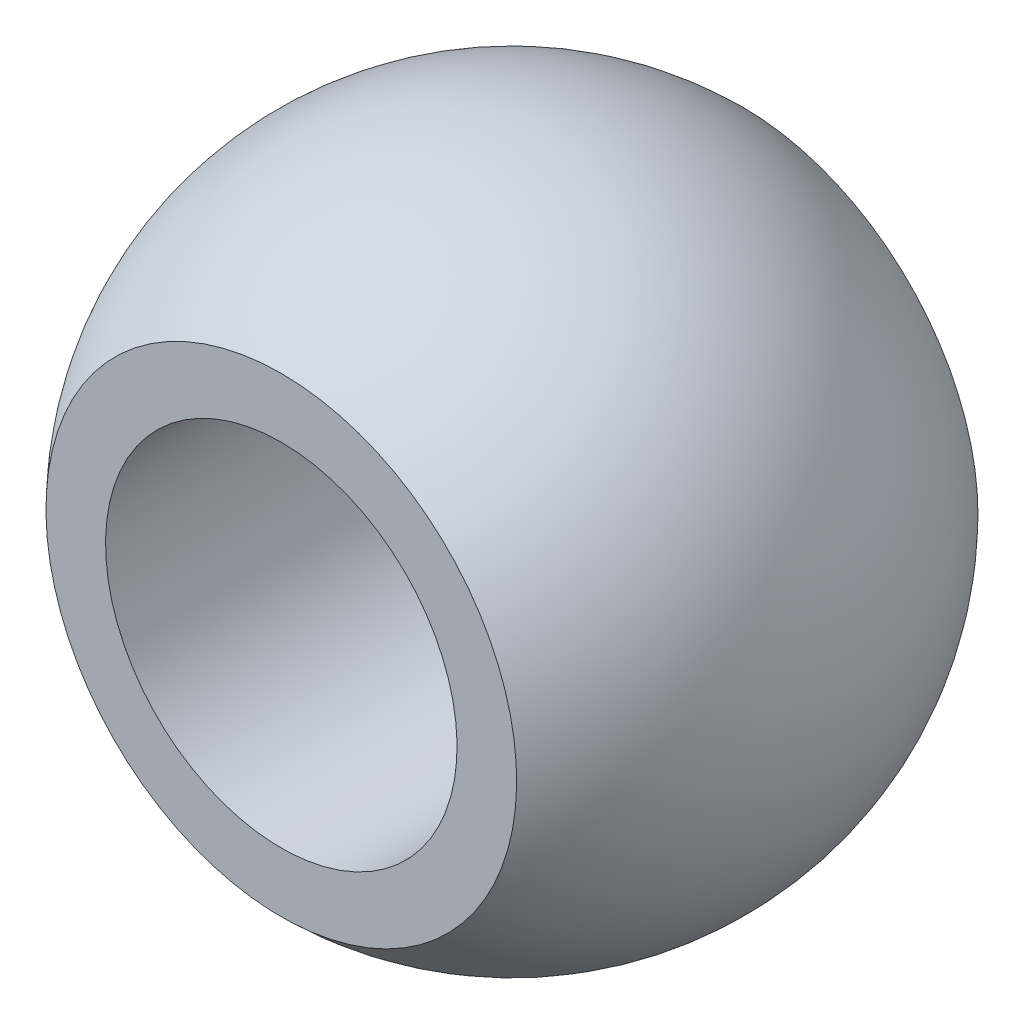
from build123d import *
from build123d.topology import SkipClean

# Parameters (mm, degrees)
CROQUIS2_R                 = 8
CORTAR_EXTRUIR1_DEPTH      = 26.980762114
CORTAR_EXTRUIR1_DEPTH_BACK = 26.980762114
CROQUIS3_W                 = 10
CROQUIS3_H                 = 21.424285286
CORTAR_EXTRUIR2_DEPTH      = 26.980762114
CORTAR_EXTRUIR2_DEPTH_BACK = 26.980762114


with BuildPart() as part:
    # Croquis1 → Revolución1 (revolve)
    with BuildSketch(Plane.XY):
        with BuildLine():
            Line((0, 15), (0, -15))
            ThreePointArc((0, -15), (-15, 0), (0, 15))
        make_face()
    revolve(axis=Axis((0, 15, 0), (0, -1, 0)))

    # Croquis2 → Cortar-Extruir1 (cut, two sides)
    with BuildSketch(Plane.XY) as cortar_extruir1_sk:
        with Locations(Location((0, 0, 0), (0, 0, 180))):
            Circle(CROQUIS2_R)
    extrude(amount=CORTAR_EXTRUIR1_DEPTH, mode=Mode.SUBTRACT)
    extrude(cortar_extruir1_sk.sketch, amount=-CORTAR_EXTRUIR1_DEPTH_BACK, mode=Mode.SUBTRACT)

    # Croquis3 → Cortar-Extruir2 (cut, two sides)
    with SkipClean():  # the faces are left unmerged after this step: merging them gives an invalid solid
        with BuildSketch(Plane(origin=(0, 0, 0), x_dir=(0, 0, -1), z_dir=(1, 0, 0))) as cortar_extruir2_sk:
            with Locations((-15.5, 0)):
                Rectangle(CROQUIS3_W, CROQUIS3_H)
            with Locations((15.5, 0)):
                Rectangle(CROQUIS3_W, CROQUIS3_H)
        extrude(amount=CORTAR_EXTRUIR2_DEPTH, mode=Mode.SUBTRACT)
        extrude(cortar_extruir2_sk.sketch, amount=-CORTAR_EXTRUIR2_DEPTH_BACK, mode=Mode.SUBTRACT)


solid = part.part
